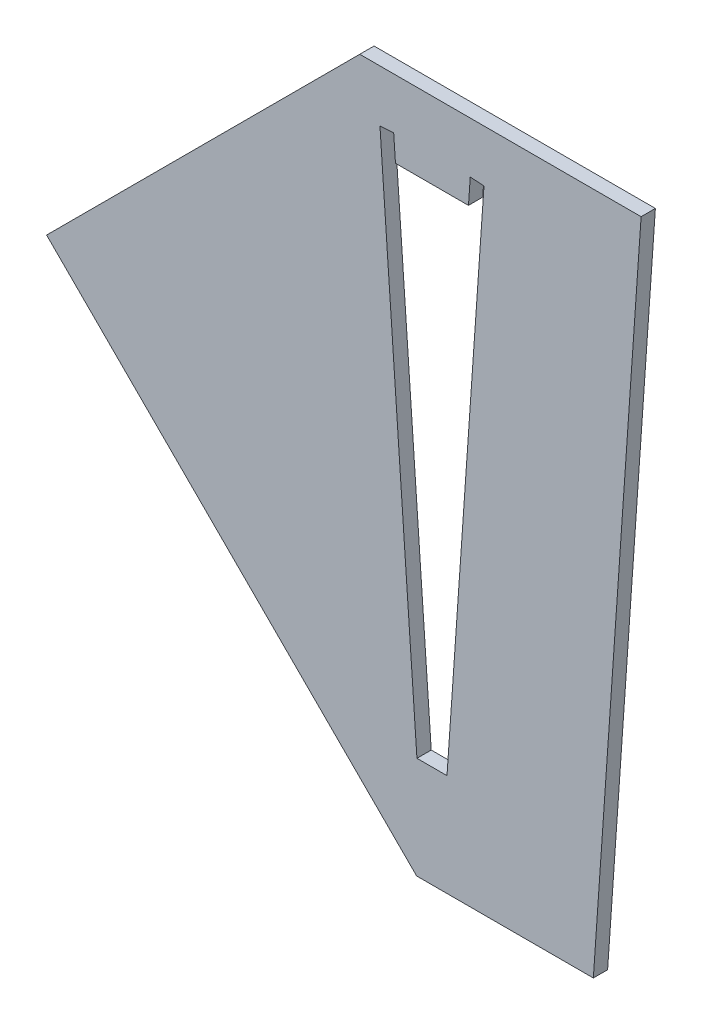
from build123d import *

# Parameters (mm, degrees)
BOSS_EXTRUDE1_DEPTH = 2.8


with BuildPart() as part:
    # Sketch1 → Boss-Extrude1 (new body)
    with BuildSketch(Plane.XY):
        Polygon((40.979118187, 112.870740647), (-14.14721608, 112.870740647), (-75.508978364, 51.508978364), (-3, -21), (31.617964081, -21), align=None)
        Polygon((-2.943243377, -1), (2.943243377, -1), (10.193422936, 102.682398168), (7.5, 102.870740647), (7.15036594, 97.870740647), (-7.15036594, 97.870740647), (-7.5, 102.870740647), (-10.193422936, 102.682398168), align=None, mode=Mode.SUBTRACT)
    extrude(amount=BOSS_EXTRUDE1_DEPTH)


solid = part.part
